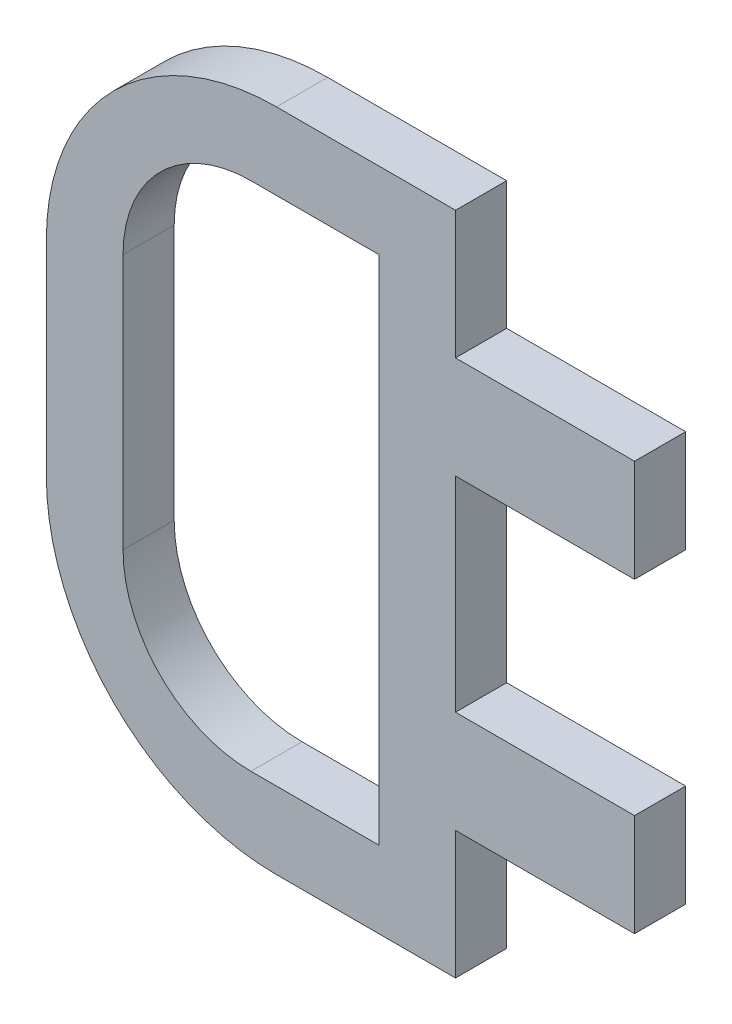
from build123d import *

# Parameters (mm, degrees)
BOSS_EXTRU_1_DEPTH = 10
ESQUISSE2_W        = 35
ESQUISSE2_H        = 20
BOSS_EXTRU_2_DEPTH = 10


with BuildPart() as part:
    # Esquisse1 → Boss.-Extru.1 (new body)
    with BuildSketch(Plane.XY):
        with BuildLine():
            Line((5, 65), (40, 65))
            Line((40, 65), (40, -65))
            Line((40, -65), (5, -65))
            ThreePointArc((5, -65), (-26.819805153, -51.819805153), (-40, -20))
            Line((-40, -20), (-40, 20))
            ThreePointArc((-40, 20), (-26.819805153, 51.819805153), (5, 65))
        make_face()
        with BuildLine():
            Line((0, 50), (25, 50))
            Line((25, 50), (25, -50))
            Line((25, -50), (0, -50))
            ThreePointArc((0, -50), (-17.67766953, -42.67766953), (-25, -25))
            Line((-25, -25), (-25, 25))
            ThreePointArc((-25, 25), (-17.67766953, 42.67766953), (0, 50))
        make_face(mode=Mode.SUBTRACT)
    extrude(amount=BOSS_EXTRU_1_DEPTH)

    # Esquisse2 → Boss.-Extru.2 (add)
    with BuildSketch(Plane.XY.offset(10)):
        with Locations((57.5, 30)):
            Rectangle(ESQUISSE2_W, ESQUISSE2_H)
        with Locations((57.5, -30)):
            Rectangle(ESQUISSE2_W, ESQUISSE2_H)
    extrude(amount=-BOSS_EXTRU_2_DEPTH)


solid = part.part
